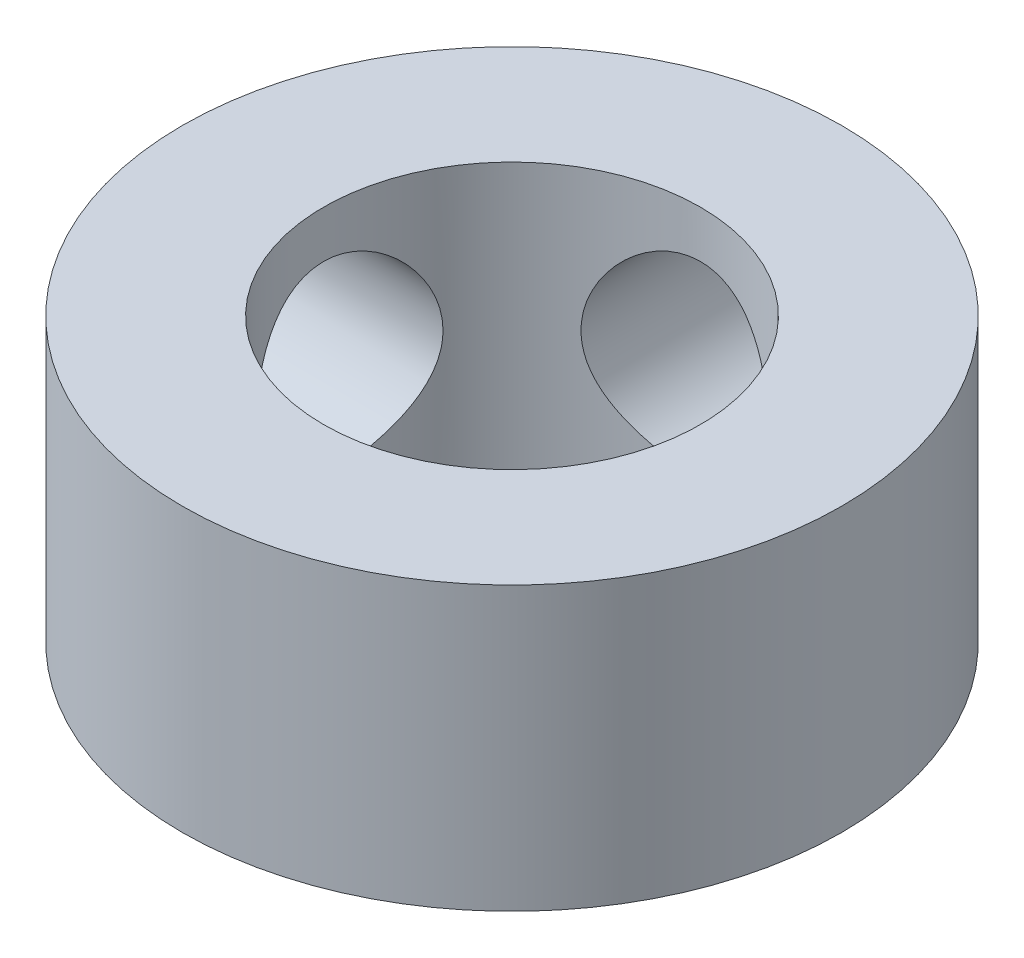
from build123d import *

# Parameters (mm, degrees)
SKETCH_1_R          = 7
SKETCH_1_R_2        = 4
EXTRUDE_1_DEPTH     = 6
SKETCH_2_R          = 2
CUT_EXTRUDE_1_DEPTH = 10
SKETCH_3_R          = 2
CUT_EXTRUDE_2_DEPTH = 10


with BuildPart() as part:
    # 草图1 → 凸台-拉伸1 (new body)
    with BuildSketch(Plane(origin=(0, 0, 0), x_dir=(1, 0, 0), z_dir=(0, 1, 0))):
        Circle(SKETCH_1_R)
        Circle(SKETCH_1_R_2, mode=Mode.SUBTRACT)
    extrude(amount=EXTRUDE_1_DEPTH)

    # 草图2 → 切除-拉伸1 (cut)
    with BuildSketch(Plane(origin=(0, 0, 0), x_dir=(0, 0, -1), z_dir=(1, 0, 0))):
        with Locations((0, 3)):
            Circle(SKETCH_2_R)
    extrude(amount=-CUT_EXTRUDE_1_DEPTH, mode=Mode.SUBTRACT)

    # 草图3 → 切除-拉伸2 (cut)
    with BuildSketch(Plane.XY):
        with Locations((0, 3)):
            Circle(SKETCH_3_R)
    extrude(amount=-CUT_EXTRUDE_2_DEPTH, mode=Mode.SUBTRACT)


solid = part.part
